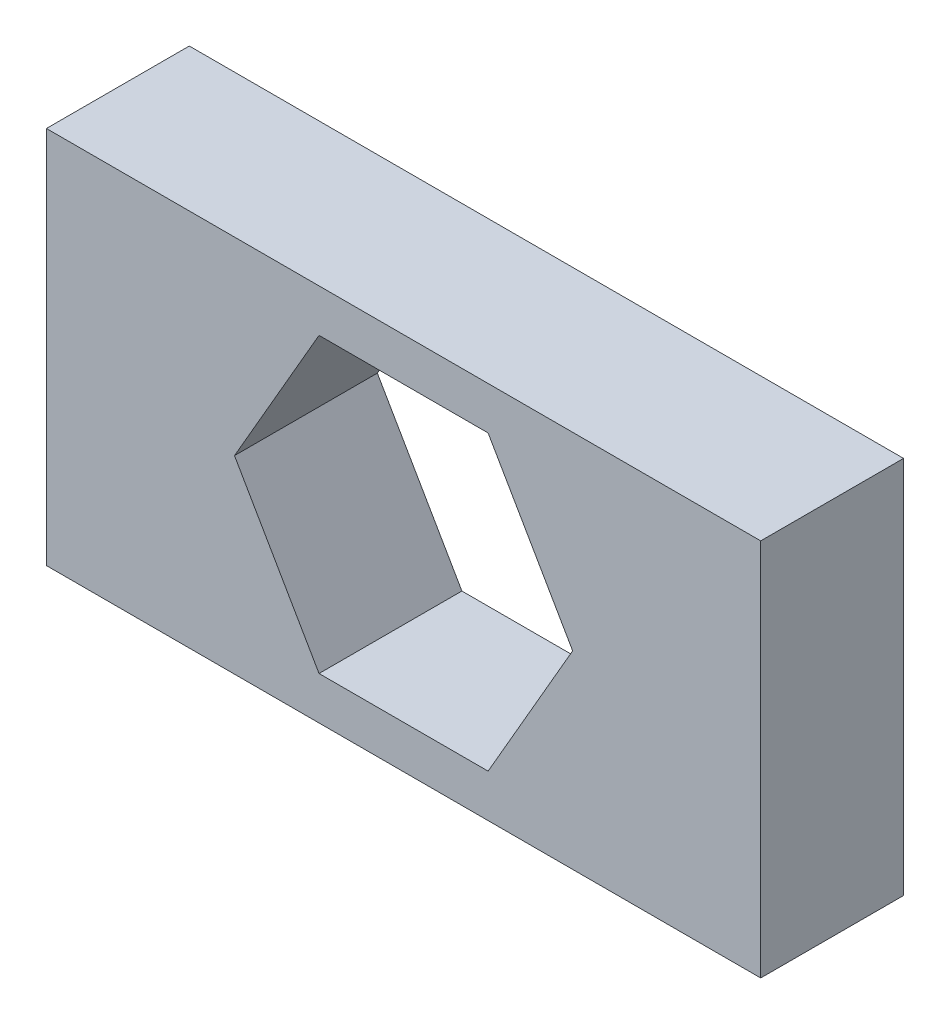
from build123d import *

# Parameters (mm, degrees)
ESBO_O1_W                = 10
ESBO_O1_H                = 5.3
RESSALTO_EXTRUS_O1_DEPTH = 2


with BuildPart() as part:
    # Esboço1 → Ressalto-extrusão1 (new body)
    with BuildSketch(Plane.XY):
        Rectangle(ESBO_O1_W, ESBO_O1_H)
        Polygon((2.367136104, 0), (1.183568052, 2.05), (-1.183568052, 2.05), (-2.367136104, 0), (-1.183568052, -2.05), (1.183568052, -2.05), align=None, mode=Mode.SUBTRACT)
    extrude(amount=RESSALTO_EXTRUS_O1_DEPTH)


solid = part.part
